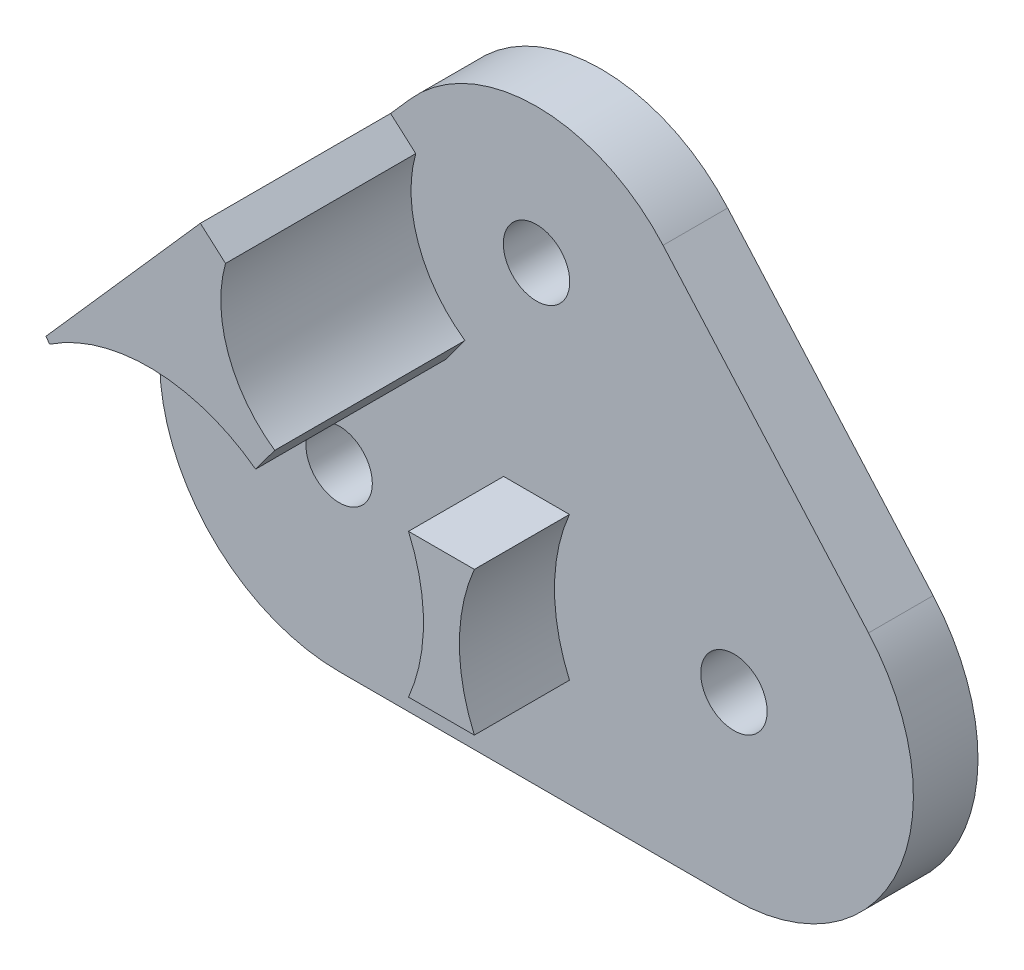
from build123d import *

# Parameters (mm, degrees)
SKETCH_1_R      = 0.925
EXTRUDE_1_DEPTH = 1.8
EXTRUDE_START   = -1.8
SKETCH_2_R      = 0.925
EXTRUDE_2_DEPTH = 1.8
EXTRUDE_3_DEPTH = 5.3
EXTRUDE_4_DEPTH = 2.65


with BuildPart() as part:
    # 草图1 → 凸台-拉伸1 (new body)
    with BuildSketch(Plane.XY):
        with BuildLine():
            Line((-8.55, 8.25), (2.45, 8.25))
            ThreePointArc((2.45, 8.25), (7.45, 3.25), (2.45, -1.75))
            Line((2.45, -1.75), (-8.55, -1.75))
            ThreePointArc((-8.55, -1.75), (-13.55, 3.25), (-8.55, 8.25))
        make_face()
        with Locations((-8.55, 3.25)):
            Circle(SKETCH_1_R, mode=Mode.SUBTRACT)
        with Locations((2.45, 3.25)):
            Circle(SKETCH_1_R, mode=Mode.SUBTRACT)
    extrude(amount=EXTRUDE_1_DEPTH)

    # 草图2 → 凸台-拉伸2 (add)
    with BuildSketch(Plane.XY.offset(1.8).offset(EXTRUDE_START)):
        with BuildLine():
            Line((-12.299646462, 6.55758997), (-6.57492094, 13.047420027))
            ThreePointArc((-6.57492094, 13.047420027), (-3.05, 14.638399767), (0.47492094, 13.047420027))
            Line((0.47492094, 13.047420027), (6.199646462, 6.55758997))
            ThreePointArc((6.199646462, 6.55758997), (4.506945569, 7.807299082), (2.45, 8.25))
            Line((2.45, 8.25), (-8.55, 8.25))
            ThreePointArc((-8.55, 8.25), (-10.606945569, 7.807299082), (-12.299646462, 6.55758997))
        make_face()
        with Locations((-3.05, 10.863062049)):
            Circle(SKETCH_2_R, mode=Mode.SUBTRACT)
    extrude(amount=EXTRUDE_2_DEPTH)

    # 草图3 → 凸台-拉伸3 (add)
    with BuildSketch(Plane.XY.offset(1.8)):
        with BuildLine():
            Line((-7.116209234, 12.433789028), (-11.416941699, 7.558267449))
            Line((-11.416941699, 7.558267449), (-11.319997249, 7.412585163))
            ThreePointArc((-11.319997249, 7.412585163), (-8.425967454, 8.248461356), (-5.576956996, 7.270076529))
            Line((-5.576956996, 7.270076529), (-5.044384077, 7.990208692))
            ThreePointArc((-5.044384077, 7.990208692), (-6.342261306, 9.683286753), (-6.415115625, 11.815349339))
            Line((-6.415115625, 11.815349339), (-7.116209234, 12.433789028))
        make_face()
    extrude(amount=EXTRUDE_3_DEPTH)

    # 草图3<3> → 凸台-拉伸4 (add)
    with BuildSketch(Plane.XY.offset(1.8)):
        with BuildLine():
            Line((-2.132575695, 5.25), (-3.967424305, 5.25))
            ThreePointArc((-3.967424305, 5.25), (-3.55, 3.25), (-3.967424305, 1.25))
            Line((-3.967424305, 1.25), (-2.132575695, 1.25))
            ThreePointArc((-2.132575695, 1.25), (-2.55, 3.25), (-2.132575695, 5.25))
        make_face()
    extrude(amount=EXTRUDE_4_DEPTH)


solid = part.part
